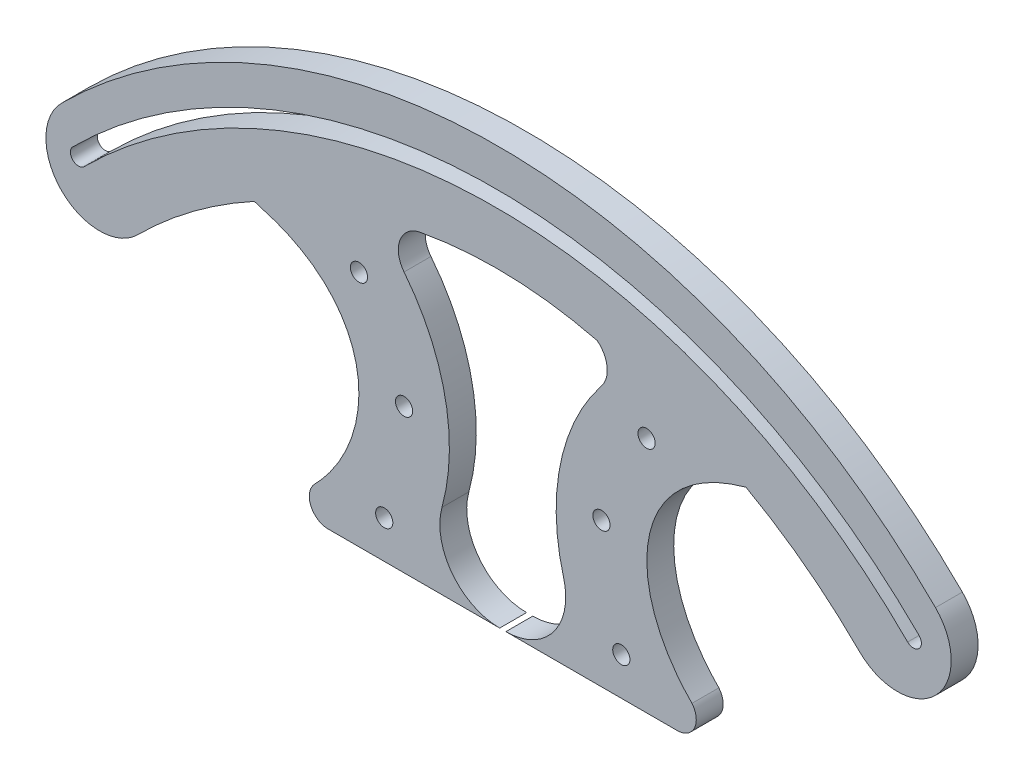
from build123d import *

# Parameters (mm, degrees)
SKETCH1_R           = 1.6
BOSS_EXTRUDE1_DEPTH = 5


with BuildPart() as part:
    # Sketch1 → Boss-Extrude1 (new body)
    with BuildSketch(Plane.XY):
        with BuildLine():
            Line((-24.374481213, 29.452498133), (-0.573242194, 29.452498133))
            ThreePointArc((-0.573242194, 29.452498133), (-9.427933785, 33.83519482), (-11.31305575, 43.533643593))
            ThreePointArc((-11.31305575, 43.533643593), (-10.722602644, 61.575298771), (-18.364057527, 77.929445758))
            ThreePointArc((-18.364057527, 77.929445758), (-19.094832363, 82.778042962), (-15.26841437, 85.8442217))
            ThreePointArc((-15.26841437, 85.8442217), (1.199883283, 87.104187108), (17.561282991, 84.846546742))
            ThreePointArc((17.561282991, 84.846546742), (19.39962033, 81.554763647), (18.364057527, 77.929445758))
            ThreePointArc((18.364057527, 77.929445758), (10.722602644, 61.575298771), (11.31305575, 43.533643593))
            ThreePointArc((11.31305575, 43.533643593), (9.427933785, 33.83519482), (0.573242194, 29.452498133))
            Line((0.573242194, 29.452498133), (24.374481213, 29.452498133))
            Line((24.374481213, 29.452498133), (32.479003365, 29.452498133))
            ThreePointArc((32.479003365, 29.452498133), (35.662704371, 31.470373288), (35.196724718, 35.210779041))
            add(Edge.make_bspline(
                [(45.242051564, 75.05397765), (30.132062398, 70.946476879), (22.540088549, 54.680703196), (31.199508073, 39.237934138), (35.196724718, 35.210779041)],
                knots=[0.154808761, 0.154808761, 0.154808761, 0.154808761, 0.468621415, 0.608629265, 0.608629265, 0.608629265, 0.608629265], degree=3))
            ThreePointArc((45.242051564, 75.05397765), (56.35651155, 67.837262053), (66.358030541, 59.143481365))
            ThreePointArc((66.358030541, 59.143481365), (80.500166165, 59.143481365), (80.500166165, 73.285616989))
            ThreePointArc((80.500166165, 73.285616989), (-0.785450823, 106.955221971), (-82.071067812, 73.285616989))
            ThreePointArc((-82.071067812, 73.285616989), (-82.071067758, 59.143481311), (-67.928932081, 59.143481472))
            ThreePointArc((-67.928932081, 59.143481472), (-57.661393829, 68.036973299), (-46.22992721, 75.374419011))
            add(Edge.make_bspline(
                [(-45.055737448, 75), (-46.22992721, 75.374419011)],
                knots=[0, 0, 1, 1], degree=1))
            add(Edge.make_bspline(
                [(-45.055737448, 75), (-29.945748281, 70.892499229), (-22.599492553, 54.774229637), (-31.125849983, 39.411271255), (-35.001982205, 35.428245813)],
                knots=[0.154808761, 0.154808761, 0.154808761, 0.154808761, 0.468621415, 0.60616707, 0.60616707, 0.60616707, 0.60616707], degree=3))
            ThreePointArc((-35.001982205, 35.428245813), (-35.72226494, 31.603661743), (-32.479003365, 29.452498133))
            Line((-32.479003365, 29.452498133), (-24.374481213, 29.452498133))
        make_face()
        with Locations((-22.052924911, 36.483296004)):
            Circle(SKETCH1_R, mode=Mode.SUBTRACT)
        with Locations((-18.364057527, 56.292076909)):
            Circle(SKETCH1_R, mode=Mode.SUBTRACT)
        with Locations((22.052924912, 36.483296004)):
            Circle(SKETCH1_R, mode=Mode.SUBTRACT)
        with Locations((18.364057527, 56.292076909)):
            Circle(SKETCH1_R, mode=Mode.SUBTRACT)
        with Locations((-26.753522246, 73.691170186)):
            Circle(SKETCH1_R, mode=Mode.SUBTRACT)
        with BuildLine():
            ThreePointArc((-80.002588236, 67.275209348), (-1.278913793, 99.883622983), (77.44476065, 67.275209348))
            ThreePointArc((77.44476065, 67.275209348), (77.44476065, 65.153889005), (75.323440307, 65.153889005))
            ThreePointArc((75.323440307, 65.153889005), (-1.278913793, 96.883622983), (-77.881267893, 65.153889005))
            ThreePointArc((-77.881267893, 65.153889005), (-80.002588236, 65.153889005), (-80.002588236, 67.275209348))
        make_face(mode=Mode.SUBTRACT)
        with Locations((26.753522246, 73.691170186)):
            Circle(SKETCH1_R, mode=Mode.SUBTRACT)
    extrude(amount=BOSS_EXTRUDE1_DEPTH)


solid = part.part
